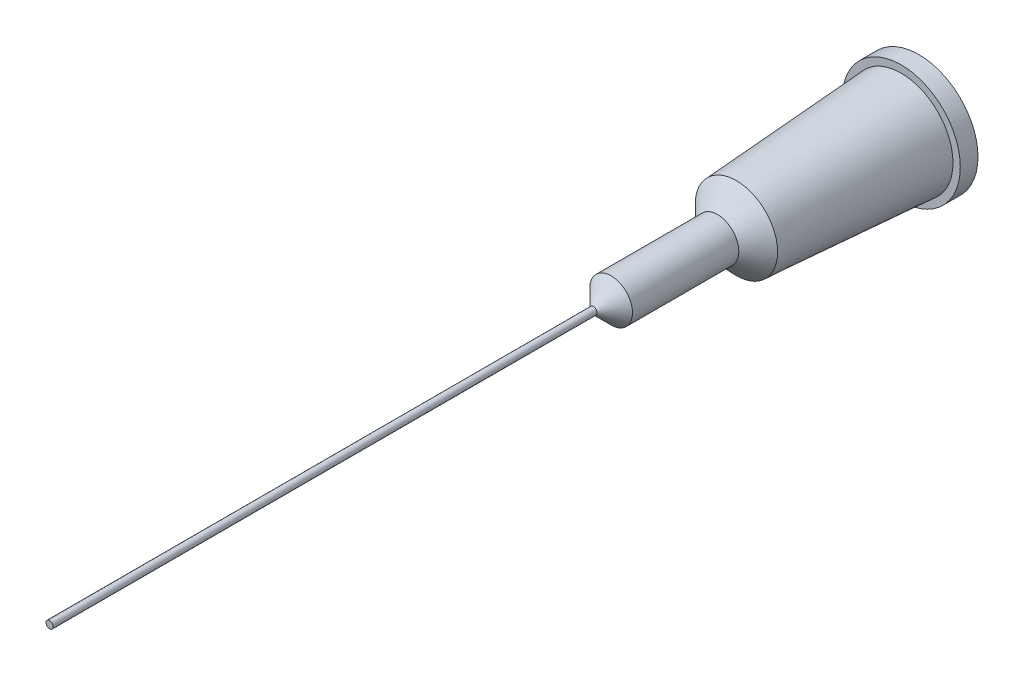
from build123d import *


with BuildPart() as part:
    # Sketch1 → Revolve1 (revolve)
    with BuildSketch(Plane(origin=(0, 0, 0), x_dir=(1, 0, 0), z_dir=(0, 1, 0))):
        Polygon((-3.335, 0), (-3.335, -1), (-2.925, -1), (-2.325, -10.3), (-1.205, -11.37), (-1.205, -17.37), (-0.205, -18.37), (-0.205, -49.06), (0, -49.06), (0, 0), align=None)
    revolve(axis=Axis((0, 0, 49.06), (0, 0, -1)))


solid = part.part
